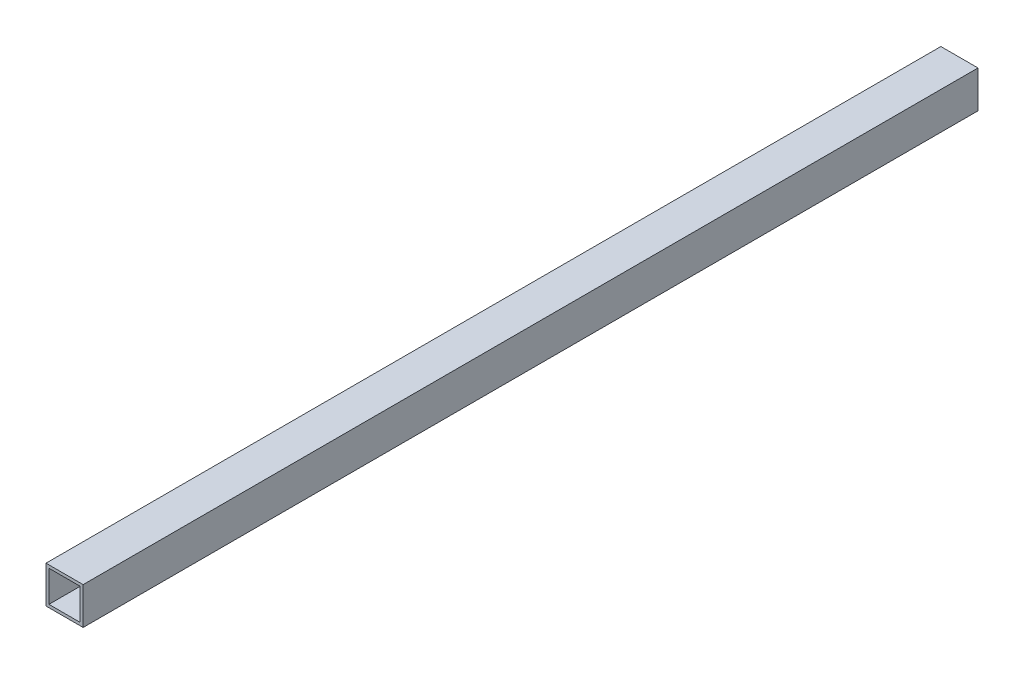
from build123d import *

# Parameters (mm, degrees)
SKETCH1_W           = 25.4
SKETCH1_H           = 25.4
SKETCH1_W_2         = 21.4
SKETCH1_H_2         = 21.4
BOSS_EXTRUDE1_DEPTH = 612


with BuildPart() as part:
    # Sketch1 → Boss-Extrude1 (new body)
    with BuildSketch(Plane.XY):
        Rectangle(SKETCH1_W, SKETCH1_H)
        Rectangle(SKETCH1_W_2, SKETCH1_H_2, mode=Mode.SUBTRACT)
    extrude(amount=BOSS_EXTRUDE1_DEPTH)


solid = part.part
